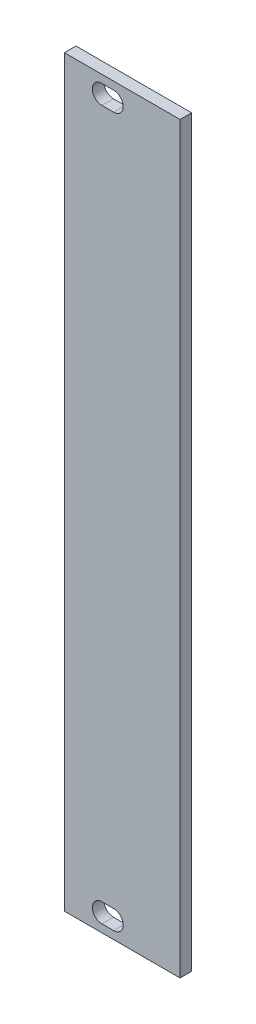
from build123d import *

# Parameters (mm, degrees)
SKETCH1_W           = 20
SKETCH1_H           = 128.5
BOSS_EXTRUDE1_DEPTH = 2


with BuildPart() as part:
    # Sketch1 → Boss-Extrude1 (new body)
    with BuildSketch(Plane.XY):
        Rectangle(SKETCH1_W, SKETCH1_H)
        with BuildLine():
            Line((-3.516, -59.6), (-1.484, -59.6))
            ThreePointArc((-1.484, -59.6), (0.166, -61.25), (-1.484, -62.9))
            Line((-1.484, -62.9), (-3.516, -62.9))
            ThreePointArc((-3.516, -62.9), (-5.166, -61.25), (-3.516, -59.6))
        make_face(mode=Mode.SUBTRACT)
        with BuildLine():
            Line((-3.516, 62.9), (-1.484, 62.9))
            ThreePointArc((-1.484, 62.9), (0.166, 61.25), (-1.484, 59.6))
            Line((-1.484, 59.6), (-3.516, 59.6))
            ThreePointArc((-3.516, 59.6), (-5.166, 61.25), (-3.516, 62.9))
        make_face(mode=Mode.SUBTRACT)
    extrude(amount=BOSS_EXTRUDE1_DEPTH)


solid = part.part
